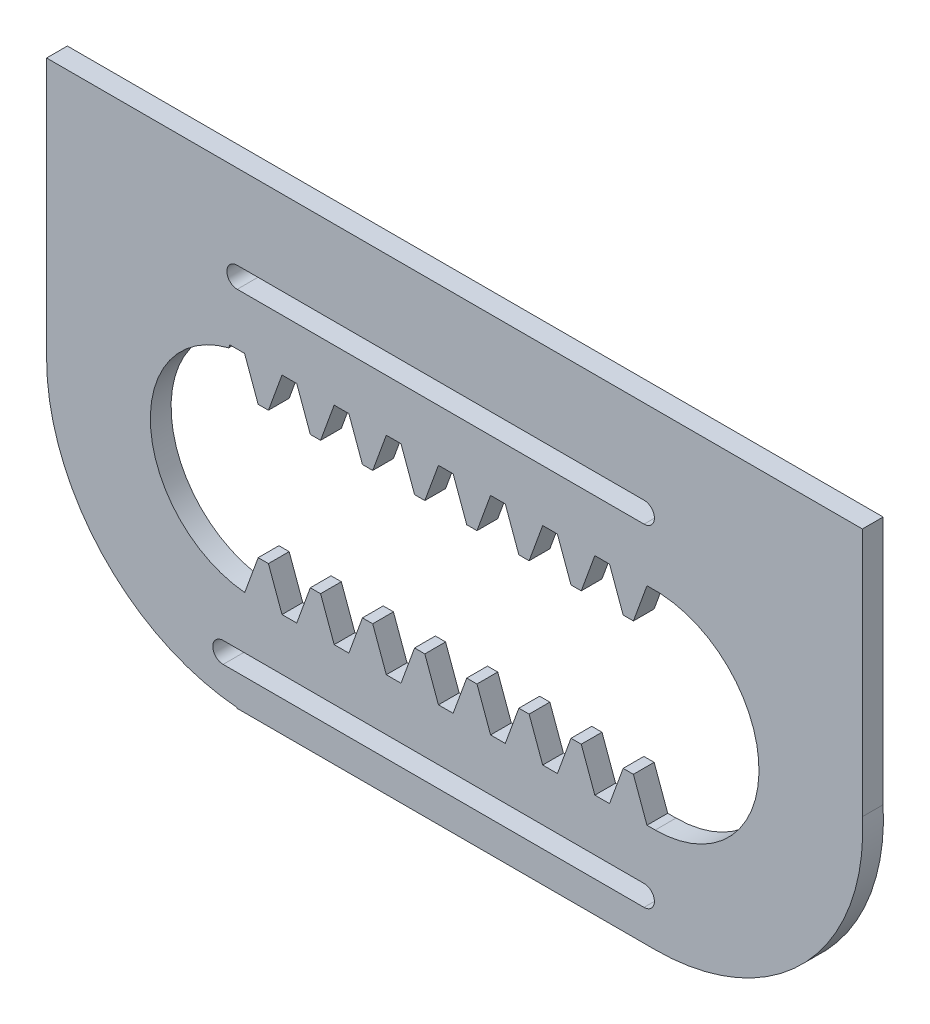
from build123d import *

# Parameters (mm, degrees)
BLANKSKE_W           = 127
BLANKSKE_H           = 43.18
BLANK_DEPTH          = 25.4
TOOTHCUTSIM_DEPTH    = 137.523523248
TEETHCUTS_COUNT      = 9
TEETHCUTS_PITCH      = 15.959290662
BOSS_EXTRUDE1_DEPTH  = 25.4
MIRROR1_COPY_1_DEPTH = 137.523523248
MIRROR1_COPY_2_DEPTH = 137.523523248
MIRROR1_COPY_3_DEPTH = 137.523523248
MIRROR1_COPY_4_DEPTH = 137.523523248
MIRROR1_COPY_5_DEPTH = 137.523523248
MIRROR1_COPY_6_DEPTH = 137.523523248
MIRROR1_COPY_7_DEPTH = 137.523523248
MIRROR1_COPY_8_DEPTH = 137.523523248
CUT_EXTRUDE1_DEPTH   = 232.151804304
SKETCH5_W            = 249.809436719
SKETCH5_H            = 19.05
CUT_EXTRUDE2_DEPTH   = 232.151804304
BOSS_EXTRUDE2_DEPTH  = 6.35


with BuildPart() as part:
    # BlankSke → Blank (new body)
    with BuildSketch(Plane.XY):
        with Locations((63.5, 21.59)):
            Rectangle(BLANKSKE_W, BLANKSKE_H)
    blank = extrude(amount=-BLANK_DEPTH)

    # TooCutSkeSim → ToothCutSim (cut, through all)
    with BuildSketch(Plane.XY):
        Polygon((2.250111678, 31.75), (-2.250111678, 31.75), (-6.4195363, 43.2054), (6.4195363, 43.2054), align=None)
    toothcutsim = extrude(amount=-TOOTHCUTSIM_DEPTH, mode=Mode.SUBTRACT)

    # TeethCuts: ToothCutSim ×9
    with Locations(*[(i * TEETHCUTS_PITCH, 0, 0) for i in range(1, TEETHCUTS_COUNT)]):
        add(toothcutsim, mode=Mode.SUBTRACT)

    # Sketch3 → Boss-Extrude1 (add)
    with BuildSketch(Plane(origin=(0, 0, -25.4), x_dir=(-1, 0, 0), z_dir=(0, 0, -1))):
        with BuildLine():
            Line((-127.960169835, 127), (-5.150733116, 127))
            ThreePointArc((-5.150733116, 127), (58.349266884, 63.5), (-5.150733116, 0))
            Line((-5.150733116, 0), (-127.960169835, 0))
            ThreePointArc((-127.960169835, 0), (-191.460169835, 63.5), (-127.960169835, 127))
        make_face()
        with BuildLine():
            Line((-127.960169835, 95.25), (-5.150733116, 95.25))
            ThreePointArc((-5.150733116, 95.25), (26.599266884, 63.5), (-5.150733116, 31.75))
            Line((-5.150733116, 31.75), (-127.960169835, 31.75))
            ThreePointArc((-127.960169835, 31.75), (-159.710169835, 63.5), (-127.960169835, 95.25))
        make_face(mode=Mode.SUBTRACT)
    extrude(amount=-BOSS_EXTRUDE1_DEPTH)

    # Mirror1: Blank, ToothCutSim across plane
    add(blank.mirror(Plane.ZX.offset(63.5)))
    add(toothcutsim.mirror(Plane.ZX.offset(63.5)), mode=Mode.SUBTRACT)

    # Mirror1 copy 1 sketch → Mirror1 copy 1 (cut, through all)
    with BuildSketch(Plane(origin=(15.959290662, 127, 0), x_dir=(1, 0, 0), z_dir=(0, 0, 1))):
        Polygon((2.250111678, -31.75), (-2.250111678, -31.75), (-6.4195363, -43.2054), (6.4195363, -43.2054), align=None)
    extrude(amount=-MIRROR1_COPY_1_DEPTH, mode=Mode.SUBTRACT)

    # Mirror1 copy 2 sketch → Mirror1 copy 2 (cut, through all)
    with BuildSketch(Plane(origin=(31.918581324, 127, 0), x_dir=(1, 0, 0), z_dir=(0, 0, 1))):
        Polygon((2.250111678, -31.75), (-2.250111678, -31.75), (-6.4195363, -43.2054), (6.4195363, -43.2054), align=None)
    extrude(amount=-MIRROR1_COPY_2_DEPTH, mode=Mode.SUBTRACT)

    # Mirror1 copy 3 sketch → Mirror1 copy 3 (cut, through all)
    with BuildSketch(Plane(origin=(47.877871986, 127, 0), x_dir=(1, 0, 0), z_dir=(0, 0, 1))):
        Polygon((2.250111678, -31.75), (-2.250111678, -31.75), (-6.4195363, -43.2054), (6.4195363, -43.2054), align=None)
    extrude(amount=-MIRROR1_COPY_3_DEPTH, mode=Mode.SUBTRACT)

    # Mirror1 copy 4 sketch → Mirror1 copy 4 (cut, through all)
    with BuildSketch(Plane(origin=(63.837162648, 127, 0), x_dir=(1, 0, 0), z_dir=(0, 0, 1))):
        Polygon((2.250111678, -31.75), (-2.250111678, -31.75), (-6.4195363, -43.2054), (6.4195363, -43.2054), align=None)
    extrude(amount=-MIRROR1_COPY_4_DEPTH, mode=Mode.SUBTRACT)

    # Mirror1 copy 5 sketch → Mirror1 copy 5 (cut, through all)
    with BuildSketch(Plane(origin=(79.79645331, 127, 0), x_dir=(1, 0, 0), z_dir=(0, 0, 1))):
        Polygon((2.250111678, -31.75), (-2.250111678, -31.75), (-6.4195363, -43.2054), (6.4195363, -43.2054), align=None)
    extrude(amount=-MIRROR1_COPY_5_DEPTH, mode=Mode.SUBTRACT)

    # Mirror1 copy 6 sketch → Mirror1 copy 6 (cut, through all)
    with BuildSketch(Plane(origin=(95.755743972, 127, 0), x_dir=(1, 0, 0), z_dir=(0, 0, 1))):
        Polygon((2.250111678, -31.75), (-2.250111678, -31.75), (-6.4195363, -43.2054), (6.4195363, -43.2054), align=None)
    extrude(amount=-MIRROR1_COPY_6_DEPTH, mode=Mode.SUBTRACT)

    # Mirror1 copy 7 sketch → Mirror1 copy 7 (cut, through all)
    with BuildSketch(Plane(origin=(111.715034634, 127, 0), x_dir=(1, 0, 0), z_dir=(0, 0, 1))):
        Polygon((2.250111678, -31.75), (-2.250111678, -31.75), (-6.4195363, -43.2054), (6.4195363, -43.2054), align=None)
    extrude(amount=-MIRROR1_COPY_7_DEPTH, mode=Mode.SUBTRACT)

    # Mirror1 copy 8 sketch → Mirror1 copy 8 (cut, through all)
    with BuildSketch(Plane(origin=(127.674325296, 127, 0), x_dir=(1, 0, 0), z_dir=(0, 0, 1))):
        Polygon((2.250111678, -31.75), (-2.250111678, -31.75), (-6.4195363, -43.2054), (6.4195363, -43.2054), align=None)
    extrude(amount=-MIRROR1_COPY_8_DEPTH, mode=Mode.SUBTRACT)

    # Sketch4 → Cut-Extrude1 (cut, through all)
    with BuildSketch(Plane(origin=(0, 0, -25.4), x_dir=(-1, 0, 0), z_dir=(0, 0, -1))):
        with BuildLine():
            Line((4.314647241, 9.525), (-124.523078394, 9.525))
            ThreePointArc((-124.523078394, 9.525), (-127.698078394, 12.7), (-124.523078394, 15.875))
            Line((-124.523078394, 15.875), (4.314647241, 15.875))
            ThreePointArc((4.314647241, 15.875), (7.489647241, 12.7), (4.314647241, 9.525))
        make_face()
        with BuildLine():
            Line((0, 111.125), (-124.523078394, 111.125))
            ThreePointArc((-124.523078394, 111.125), (-127.698078394, 114.3), (-124.523078394, 117.475))
            Line((-124.523078394, 117.475), (0, 117.475))
            ThreePointArc((0, 117.475), (3.175, 114.3), (0, 111.125))
        make_face()
    extrude(amount=-CUT_EXTRUDE1_DEPTH, mode=Mode.SUBTRACT)

    # Sketch5 → Cut-Extrude2 (cut, through all)
    with BuildSketch(Plane(origin=(0, 0, 0), x_dir=(1, 0, 0), z_dir=(0, 1, 0))):
        with Locations((66.555451476, 9.525)):
            Rectangle(SKETCH5_W, SKETCH5_H)
    extrude(amount=CUT_EXTRUDE2_DEPTH, mode=Mode.SUBTRACT)

    # Sketch6 → Boss-Extrude2 (add)
    with BuildSketch(Plane(origin=(0, 0, -25.4), x_dir=(-1, 0, 0), z_dir=(0, 0, -1))):
        Polygon((-191.364398064, 117.861523458), (-191.364398064, 143.261523458), (58.349266884, 143.261523458), (58.349266884, 117.861523458), (58.349266884, 63.5), (13.664264486, 117.861523458), (-144.531259298, 117.861523458), (-191.364398064, 66.98623618), align=None)
    extrude(amount=-BOSS_EXTRUDE2_DEPTH)


solid = part.part
